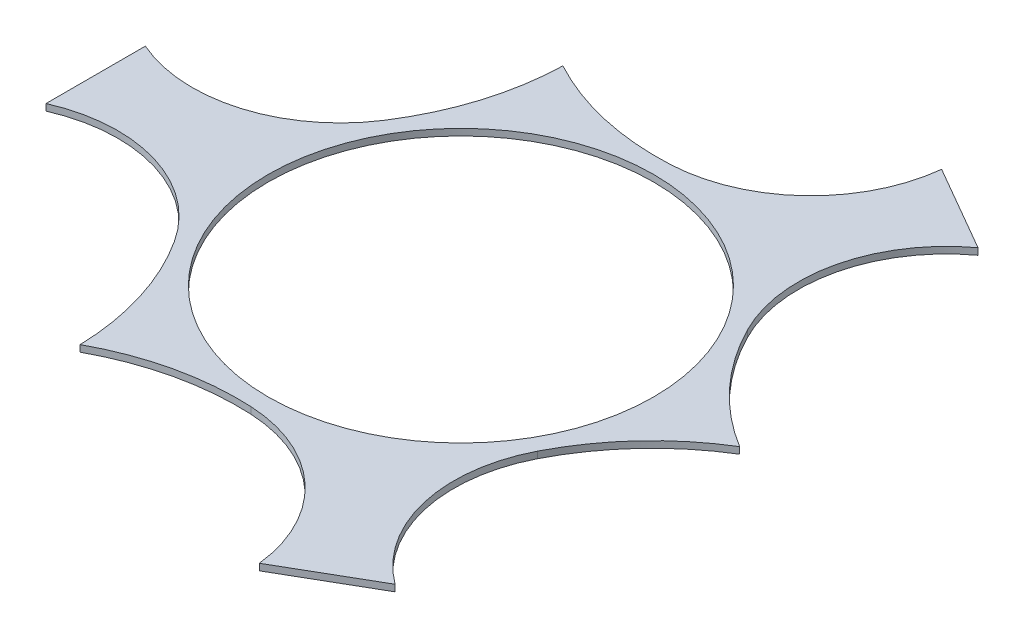
from build123d import *

# Parameters (mm, degrees)
SKETCH1_R           = 185.399607796
BOSS_EXTRUDE1_DEPTH = 6.35


with BuildPart() as part:
    # Sketch1 → Boss-Extrude1 (new body)
    with BuildSketch(Plane(origin=(0, 0, 0), x_dir=(1, 0, 0), z_dir=(0, 1, 0))):
        with BuildLine():
            Line((-351.324940876, -47.780214023), (-351.324940876, 47.780214023))
            ThreePointArc((-351.324940876, 47.780214023), (-253.254269273, 41.853018609), (-174.699704526, 100.862921435))
            ThreePointArc((-174.699704526, 100.862921435), (-145.322196596, 163.719911973), (-134.05, 232.181410755))
            ThreePointArc((-134.05, 232.181410755), (-69.124504576, 207.712669972), (0, 201.72584287))
            ThreePointArc((0, 201.72584287), (90.381357296, 240.251140111), (134.283591296, 328.146430793))
            Line((134.283591296, 328.146430793), (217.04134958, 280.366216771))
            ThreePointArc((217.04134958, 280.366216771), (162.872911977, 198.398121503), (174.699704526, 100.862921435))
            ThreePointArc((174.699704526, 100.862921435), (214.446701172, 43.992758), (268.1, 0))
            ThreePointArc((268.1, 0), (214.446701172, -43.992758), (174.699704526, -100.862921435))
            ThreePointArc((174.699704526, -100.862921435), (162.872911977, -198.398121503), (217.04134958, -280.366216771))
            Line((217.04134958, -280.366216771), (134.283591296, -328.146430793))
            ThreePointArc((134.283591296, -328.146430793), (90.381357296, -240.251140111), (0, -201.72584287))
            ThreePointArc((0, -201.72584287), (-69.124504576, -207.712669972), (-134.05, -232.181410755))
            ThreePointArc((-134.05, -232.181410755), (-145.322196596, -163.719911973), (-174.699704526, -100.862921435))
            ThreePointArc((-174.699704526, -100.862921435), (-253.254269273, -41.853018609), (-351.324940876, -47.780214023))
        make_face()
        Circle(SKETCH1_R, mode=Mode.SUBTRACT)
    extrude(amount=BOSS_EXTRUDE1_DEPTH)


solid = part.part
